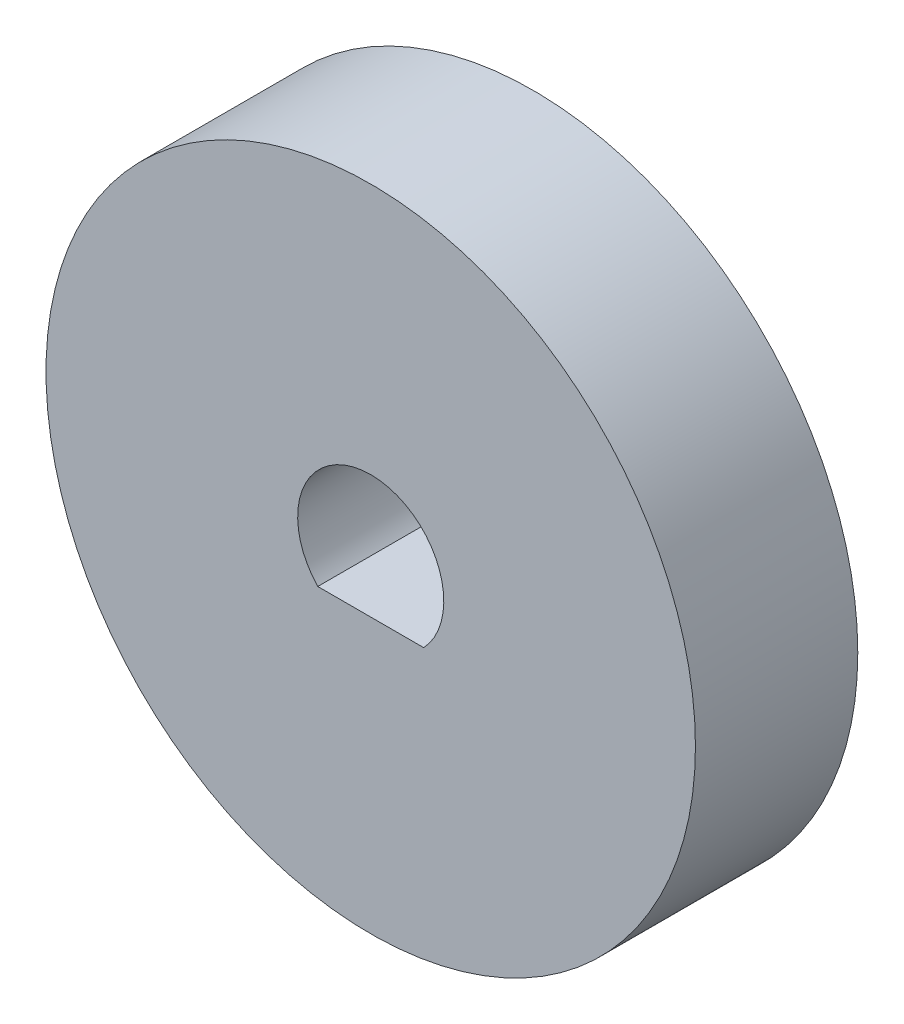
from build123d import *

# Parameters (mm, degrees)
SKETCH_1_R          = 10
EXTRUDE_2_DEPTH     = 5
CUT_EXTRUDE_2_DEPTH = 5


with BuildPart() as part:
    # Эскиз1 → Бобышка-Вытянуть2 (new body)
    with BuildSketch(Plane.XY):
        Circle(SKETCH_1_R)
    extrude(amount=EXTRUDE_2_DEPTH)

    # Эскиз3 → Вырез-Вытянуть2 (cut)
    with BuildSketch(Plane.XY.offset(5)):
        with BuildLine():
            Line((-1.630950643, -1.55), (1.630950643, -1.55))
            ThreePointArc((1.630950643, -1.55), (0, 2.25), (-1.630950643, -1.55))
        make_face()
    extrude(amount=-CUT_EXTRUDE_2_DEPTH, mode=Mode.SUBTRACT)


solid = part.part
